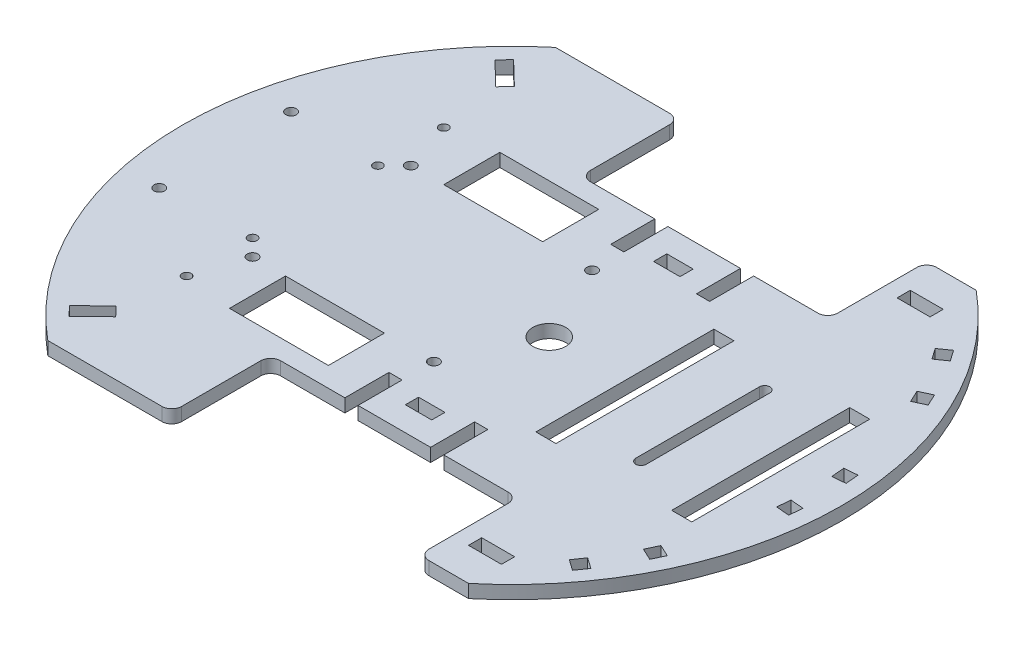
from build123d import *

# Parameters (mm, degrees)
BASIS_DEPTH        = 4
MODU_BRACKET_DEPTH = 4
SKETCH3_R          = 5
SKETCH3_W          = 75
SKETCH3_H          = 30
SKETCH3_W_2        = 8
SKETCH3_H_2        = 4
CUT_EXTRUDE2_DEPTH = 5
SKETCH4_W          = 6.1
SKETCH4_H          = 54
CUT_EXTRUDE3_DEPTH = 4
SKETCH5_W          = 4
SKETCH5_H          = 14
CUT_EXTRUDE4_DEPTH = 4
SKETCH6_W          = 10
SKETCH6_H          = 4
CUT_EXTRUDE5_DEPTH = 4
SKETCH9_R          = 1.6
SKETCH9_R_2        = 1.375
CUT_EXTRUDE7_DEPTH = 4
SKETCH10_W         = 30
SKETCH10_H         = 17
CUT_EXTRUDE8_DEPTH = 4
SKETCH11_R         = 1.6
CUT_EXTRUDE9_DEPTH = 4
FILLET1_R          = 3


with BuildPart() as part:
    # Sketch1 → Basis (new body)
    with BuildSketch(Plane(origin=(0, 0, 0), x_dir=(1, 0, 0), z_dir=(0, 1, 0))):
        with BuildLine():
            Line((63.804388564, 77), (-63.804388564, 77))
            ThreePointArc((-63.804388564, 77), (-100, 0), (-63.804388564, -77))
            Line((-63.804388564, -77), (63.804388564, -77))
            ThreePointArc((63.804388564, -77), (90.499831095, -42.541515862), (100, 0))
            ThreePointArc((100, 0), (90.499831095, 42.541515862), (63.804388564, 77))
        make_face()
    extrude(amount=BASIS_DEPTH)

    # Sketch2 → Modu bracket (cut)
    with BuildSketch(Plane(origin=(0, 4, 0), x_dir=(1, 0, 0), z_dir=(0, 1, 0))):
        Polygon((90.817009036, -6.191182133), (94.801787829, -6.539805104), (94.453164858, -10.524583897), (90.468386065, -10.175960926), align=None)
        Polygon((83.047916894, -37.86952889), (86.673148042, -39.560001937), (84.982674995, -43.185233085), (81.357443847, -41.494760038), align=None)
        Polygon((75.166261713, -52.218202052), (78.442869891, -54.512507797), (76.148564145, -57.789115975), (72.871955968, -55.494810229), align=None)
        Polygon((90.468386065, 10.175960926), (94.453164858, 10.524583897), (94.801787829, 6.539805104), (90.817009036, 6.191182133), align=None)
        Polygon((81.357443847, 41.494760038), (84.982674995, 43.185233085), (86.673148042, 39.560001937), (83.047916894, 37.86952889), align=None)
        Polygon((72.871955968, 55.494810229), (76.148564145, 57.789115975), (78.44286989, 54.512507797), (75.166261713, 52.218202052), align=None)
    extrude(amount=-MODU_BRACKET_DEPTH, mode=Mode.SUBTRACT)

    # Sketch3 → Cut-Extrude2 (cut, through all)
    with BuildSketch(Plane(origin=(0, 4, 0), x_dir=(1, 0, 0), z_dir=(0, 1, 0))):
        with Locations((11.304388564, 0)):
            Circle(SKETCH3_R)
        with Locations((11.304388564, -62)):
            Rectangle(SKETCH3_W, SKETCH3_H)
        with Locations((11.304388564, 62)):
            Rectangle(SKETCH3_W, SKETCH3_H)
        with Locations((11.304388564, -37.65)):
            Rectangle(SKETCH3_W_2, SKETCH3_H_2)
        with Locations((11.304388564, 37.65)):
            Rectangle(SKETCH3_W_2, SKETCH3_H_2)
    extrude(amount=-CUT_EXTRUDE2_DEPTH, mode=Mode.SUBTRACT)

    # Sketch4 → Cut-Extrude3 (cut)
    with BuildSketch(Plane(origin=(0, 4, 0), x_dir=(1, 0, 0), z_dir=(0, 1, 0))):
        with BuildLine():
            Line((56.282145861, -18.75), (56.282145861, 18.75))
            ThreePointArc((56.282145861, 18.75), (57.882145861, 20.35), (59.482145861, 18.75))
            Line((59.482145861, 18.75), (59.482145861, -18.75))
            ThreePointArc((59.482145861, -18.75), (57.882145861, -20.35), (56.282145861, -18.75))
        make_face()
        with Locations((78.482145861, 0)):
            Rectangle(SKETCH4_W, SKETCH4_H)
        with Locations((37.282145861, 0)):
            Rectangle(SKETCH4_W, SKETCH4_H)
    extrude(amount=-CUT_EXTRUDE3_DEPTH, mode=Mode.SUBTRACT)

    # Sketch5 → Cut-Extrude4 (cut)
    with BuildSketch(Plane(origin=(0, 4, 0), x_dir=(1, 0, 0), z_dir=(0, 1, 0))):
        with Locations((-1.695611436, -40.64)):
            Rectangle(SKETCH5_W, SKETCH5_H)
        with Locations((-1.695611436, 40.64)):
            Rectangle(SKETCH5_W, SKETCH5_H)
        with Locations((24.304388564, 40.64)):
            Rectangle(SKETCH5_W, SKETCH5_H)
        with Locations((24.304388564, -40.64)):
            Rectangle(SKETCH5_W, SKETCH5_H)
    extrude(amount=-CUT_EXTRUDE4_DEPTH, mode=Mode.SUBTRACT)

    # Sketch6 → Cut-Extrude5 (cut)
    with BuildSketch(Plane(origin=(0, 4, 0), x_dir=(1, 0, 0), z_dir=(0, 1, 0))):
        Polygon((-62.518054096, 57.592655881), (-59.739420614, 60.470015082), (-66.932818617, 67.416598787), (-69.711452099, 64.539239585), align=None)
        Polygon((-59.739420614, -60.470015082), (-62.518054096, -57.592655881), (-69.711452099, -64.539239585), (-66.932818617, -67.416598787), align=None)
        with Locations((58.804388564, -65)):
            Rectangle(SKETCH6_W, SKETCH6_H)
        with Locations((58.804388564, 65)):
            Rectangle(SKETCH6_W, SKETCH6_H)
    extrude(amount=-CUT_EXTRUDE5_DEPTH, mode=Mode.SUBTRACT)

    # Sketch9 → Cut-Extrude7 (cut)
    with BuildSketch(Plane(origin=(0, 4, 0), x_dir=(1, 0, 0), z_dir=(0, 1, 0))):
        with Locations((-54.695611436, -24)):
            Circle(SKETCH9_R)
        with Locations((-54.695611436, 24)):
            Circle(SKETCH9_R)
        with Locations((0.304388564, 24)):
            Circle(SKETCH9_R)
        with Locations((0.304388564, -24)):
            Circle(SKETCH9_R)
        with Locations((-59.695611436, 39)):
            Circle(SKETCH9_R_2)
        with Locations((-59.695611436, -19)):
            Circle(SKETCH9_R_2)
        with Locations((-59.695611436, 19)):
            Circle(SKETCH9_R_2)
        with Locations((-59.695611436, -39)):
            Circle(SKETCH9_R_2)
    extrude(amount=-CUT_EXTRUDE7_DEPTH, mode=Mode.SUBTRACT)

    # Sketch10 → Cut-Extrude8 (cut)
    with BuildSketch(Plane(origin=(0, 4, 0), x_dir=(1, 0, 0), z_dir=(0, 1, 0))):
        with Locations((-29.695611436, 32.5)):
            Rectangle(SKETCH10_W, SKETCH10_H)
        with Locations((-29.695611436, -32.5)):
            Rectangle(SKETCH10_W, SKETCH10_H)
    extrude(amount=-CUT_EXTRUDE8_DEPTH, mode=Mode.SUBTRACT)

    # Sketch11 → Cut-Extrude9 (cut)
    with BuildSketch(Plane(origin=(0, 4, 0), x_dir=(1, 0, 0), z_dir=(0, 1, 0))):
        with Locations((-87, -20)):
            Circle(SKETCH11_R)
        with Locations((-87, 20)):
            Circle(SKETCH11_R)
    extrude(amount=-CUT_EXTRUDE9_DEPTH, mode=Mode.SUBTRACT)

    # Fillet1
    fillet1_edges = [part.edges().sort_by_distance(p)[0] for p in [
        (48.804388564, 2, 77),
        (-26.195611436, 2, 77),
        (-26.195611436, 2, 47),
        (48.804388564, 2, 47),
        (48.804388564, 2, -77),
        (48.804388564, 2, -47),
        (-26.195611436, 2, -47),
        (-26.195611436, 2, -77),
    ]]
    fillet(fillet1_edges, radius=FILLET1_R)


solid = part.part
